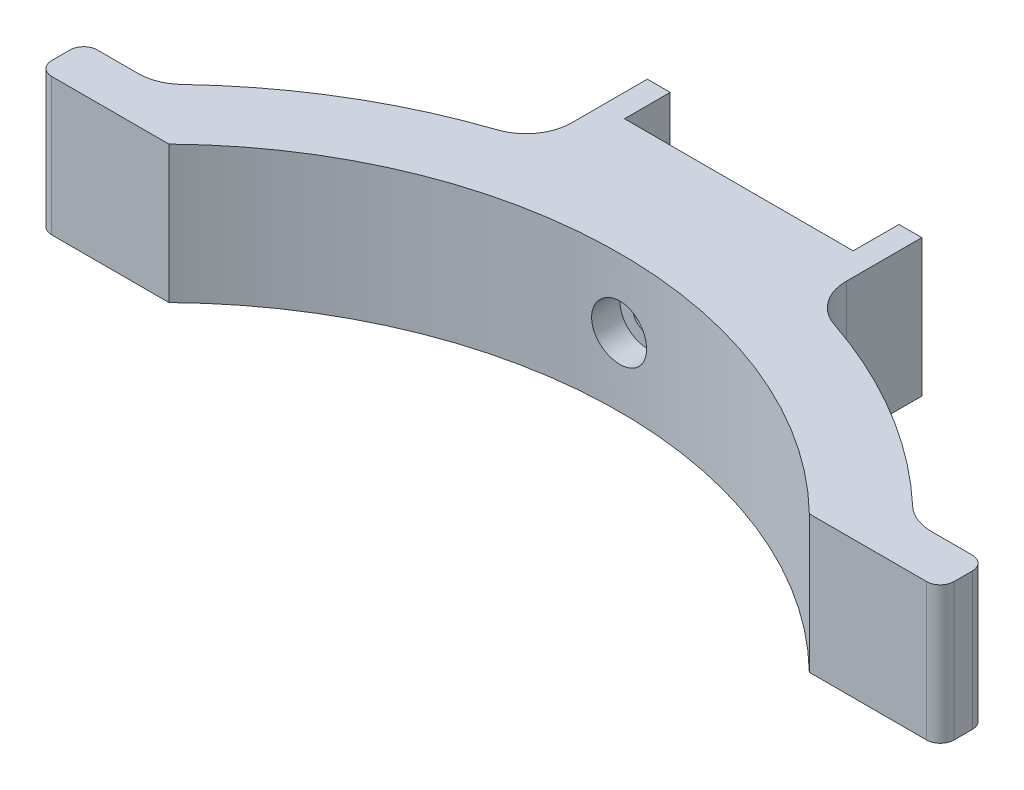
from build123d import *

# Parameters (mm, degrees)
BOSS_EXTRUDE1_DEPTH = 15
FILLET1_R           = 5
FILLET2_R           = 1.5
SKETCH2_W           = 25
SKETCH2_H           = 5
CUT_EXTRUDE1_DEPTH  = 16
SKETCH3_R           = 1.6
CUT_EXTRUDE2_DEPTH  = 28.292857857
SKETCH4_R           = 3
CUT_EXTRUDE3_DEPTH  = 17.292858


with BuildPart() as part:
    # Sketch1 → Boss-Extrude1 (new body)
    with BuildSketch(Plane(origin=(0, 0, 0), x_dir=(1, 0, 0), z_dir=(0, 1, 0))):
        with BuildLine():
            ThreePointArc((-76.314992177, 5), (-35, 22.292857857), (6.314992177, 5))
            Line((6.314992177, 5), (14.314992177, 5))
            Line((14.314992177, 5), (14.314992177, 0))
            Line((14.314992177, 0), (0, 0))
            ThreePointArc((0, 0), (-35, 14.292857857), (-70, 0))
            Line((-70, 0), (-84.314992177, 0))
            Line((-84.314992177, 0), (-84.314992177, 5))
            Line((-84.314992177, 5), (-76.314992177, 5))
        make_face()
        with BuildLine():
            Line((-50, 32.292857857), (-50, 20.319637169))
            ThreePointArc((-50, 20.319637169), (-35, 22.292857857), (-20, 20.319637169))
            Line((-20, 20.319637169), (-20, 32.292857857))
            Line((-20, 32.292857857), (-50, 32.292857857))
        make_face()
    extrude(amount=BOSS_EXTRUDE1_DEPTH)

    # Fillet1
    fillet1_edges = [part.edges().sort_by_distance(p)[0] for p in [
        (-50, 7.5, -20.319637169),
        (-20, 7.5, -20.319637169),
        (6.314992177, 7.5, -5),
        (-76.314992177, 7.5, -5),
    ]]
    fillet(fillet1_edges, radius=FILLET1_R)

    # Fillet2
    fillet2_edges = [part.edges().sort_by_distance(p)[0] for p in [
        (14.314992177, 7.5, -5),
        (14.314992177, 7.5, 0),
        (-84.314992177, 7.5, 0),
        (-84.314992177, 7.5, -5),
    ]]
    fillet(fillet2_edges, radius=FILLET2_R)

    # Sketch2 → Cut-Extrude1 (cut, through all)
    with BuildSketch(Plane(origin=(0, 15, 0), x_dir=(1, 0, 0), z_dir=(0, 1, 0))):
        with Locations((-35, 29.792857857)):
            Rectangle(SKETCH2_W, SKETCH2_H)
    extrude(amount=-CUT_EXTRUDE1_DEPTH, mode=Mode.SUBTRACT)

    # Sketch3 → Cut-Extrude2 (cut, through all)
    with BuildSketch(Plane(origin=(0, 0, -27.292857857), x_dir=(-1, 0, 0), z_dir=(0, 0, -1))):
        with Locations((35, 7.5)):
            Circle(SKETCH3_R)
    extrude(amount=-CUT_EXTRUDE2_DEPTH, mode=Mode.SUBTRACT)

    # Sketch4 → Cut-Extrude3 (cut)
    with BuildSketch(Plane.XY):
        with Locations((-35, 7.5)):
            Circle(SKETCH4_R)
    extrude(amount=-CUT_EXTRUDE3_DEPTH, mode=Mode.SUBTRACT)


solid = part.part
